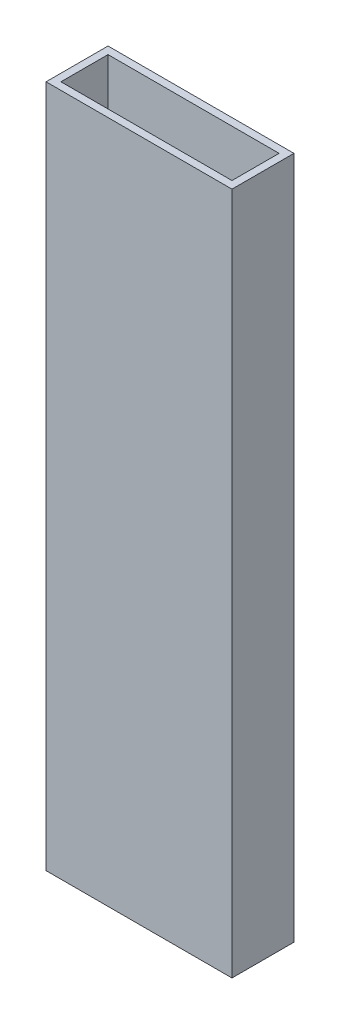
from build123d import *

# Parameters (mm, degrees)
SKETCH1_W           = 76.2
SKETCH1_H           = 25.4
SKETCH1_W_2         = 70.104
SKETCH1_H_2         = 19.304
BOSS_EXTRUDE1_DEPTH = 305.4
CUT_EXTRUDE1_START  = -12.7
SKETCH3_W           = 76.2
SKETCH3_H           = 25.4
CUT_EXTRUDE1_DEPTH  = 25.4
CUT_EXTRUDE2_START  = -12.7
SKETCH4_W           = 76.2
SKETCH4_H           = 25.4
CUT_EXTRUDE2_DEPTH  = 25.4


with BuildPart() as part:
    # Sketch1 → Boss-Extrude1 (new body)
    with BuildSketch(Plane(origin=(0, 0, 0), x_dir=(1, 0, 0), z_dir=(0, 1, 0))):
        Rectangle(SKETCH1_W, SKETCH1_H)
        Rectangle(SKETCH1_W_2, SKETCH1_H_2, mode=Mode.SUBTRACT)
    extrude(amount=BOSS_EXTRUDE1_DEPTH)

    # Sketch3 → Cut-Extrude1 (cut)
    with BuildSketch(Plane.XY.offset(CUT_EXTRUDE1_START)):
        Rectangle(SKETCH3_W, SKETCH3_H)
    extrude(amount=CUT_EXTRUDE1_DEPTH, mode=Mode.SUBTRACT)

    # Sketch4 → Cut-Extrude2 (cut)
    with BuildSketch(Plane(origin=(0, 305.4, 0), x_dir=(1, 0, 0), z_dir=(0, 0, 1)).offset(CUT_EXTRUDE2_START)):
        Rectangle(SKETCH4_W, SKETCH4_H)
    extrude(amount=CUT_EXTRUDE2_DEPTH, mode=Mode.SUBTRACT)


solid = part.part
